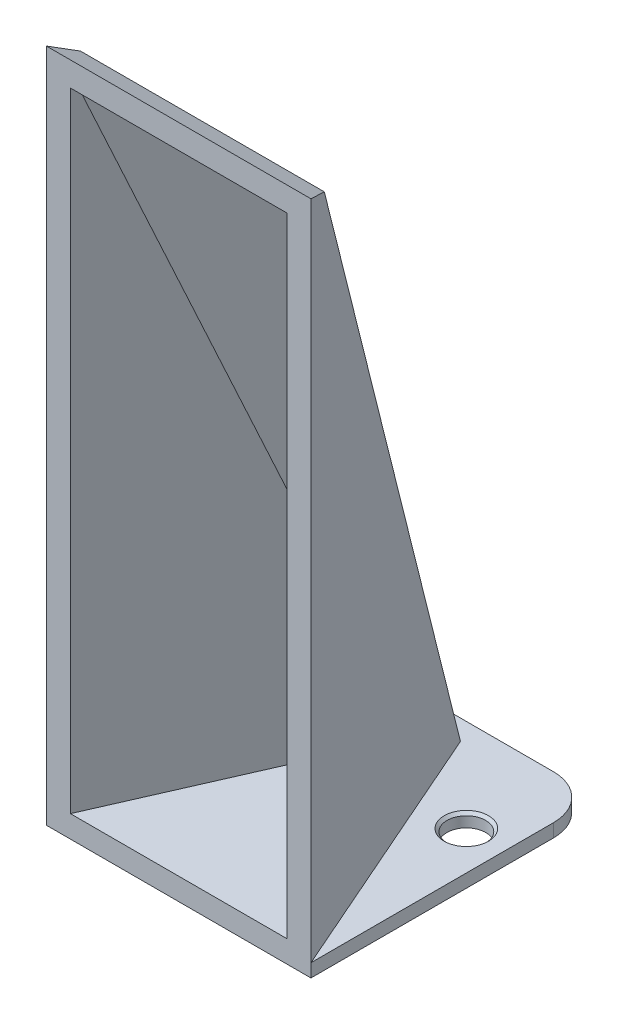
from build123d import *

# Parameters (mm, degrees)
SKETCH1_W                        = 60
SKETCH1_H                        = 65
BOSS_EXTRUDE2_DEPTH              = 3
BOSS_EXTRUDE4_DEPTH              = 150
CUT_EXTRUDE2_DEPTH               = 150
FILLET1_R                        = 10
SHELL1_T                         = -5
M10X1_25_TAPPED_HOLE1_AT_2_COUNT = 2
M10X1_25_TAPPED_HOLE1_AT_2_PITCH = 42.5


with BuildPart() as part:
    # Sketch1 → Boss-Extrude2 (new body)
    with BuildSketch(Plane(origin=(0, 0, 0), x_dir=(1, 0, 0), z_dir=(0, 1, 0))):
        with Locations((30, 32.5)):
            Rectangle(SKETCH1_W, SKETCH1_H)
    extrude(amount=BOSS_EXTRUDE2_DEPTH)

    # Sketch3 → Boss-Extrude4 (add)
    with BuildSketch(Plane(origin=(0, 3, 0), x_dir=(1, 0, 0), z_dir=(0, 1, 0))):
        Polygon((0, 0), (60, 0), (33.5, 60.392887062), (26.5, 60.392887062), align=None)
    extrude(amount=BOSS_EXTRUDE4_DEPTH)

    # Sketch5 → Cut-Extrude2 (cut)
    with BuildSketch(Plane.ZY):
        Polygon((-60.392887062, 3), (-5.391813619, 150.489864796), (0, 153), (0, 157.732510012), (-60.392887062, 157.732510012), align=None)
    extrude(amount=-CUT_EXTRUDE2_DEPTH, mode=Mode.SUBTRACT)

    # Fillet1
    fillet1_edges = [part.edges().sort_by_distance(p)[0] for p in [
        (0, 1.5, -65),
        (60, 1.5, -65),
    ]]
    fillet(fillet1_edges, radius=FILLET1_R)

    # Shell1
    shell1_openings = [part.faces().sort_by_distance(p)[0] for p in [
        (30, 52, 0),
    ]]
    offset(amount=SHELL1_T, openings=shell1_openings)

    # Sketch7 → M10x1.25 Tapped Hole1 (revolve, cut)
    with BuildSketch(Plane(origin=(51.25, 3, -43.980915379), x_dir=(0, 0, 1), z_dir=(1, 0, 0))):
        Polygon((0, 0), (0, 3), (4.4, 3), (4.4, 0.625), (5.025, 0), align=None)
    m10x1_25_tapped_hole1 = revolve(axis=Axis((51.25, 9.35, -43.980915379), (0, -1, 0)), mode=Mode.SUBTRACT)

    # M10x1.25 Tapped Hole1 at 2: M10x1.25 Tapped Hole1 ×2
    with Locations(*[(-i * M10X1_25_TAPPED_HOLE1_AT_2_PITCH, 0, 0) for i in range(1, M10X1_25_TAPPED_HOLE1_AT_2_COUNT)]):
        add(m10x1_25_tapped_hole1, mode=Mode.SUBTRACT)


solid = part.part
